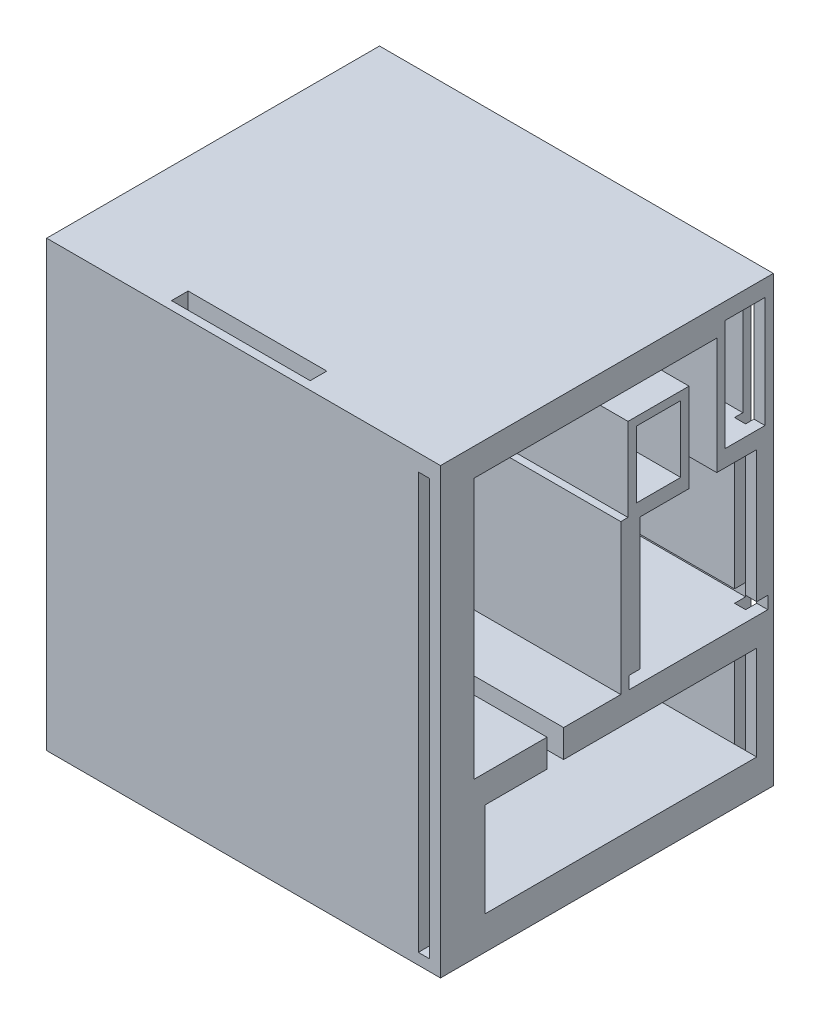
from build123d import *

# Parameters (mm, degrees)
SKETCH_1_W           = 75
SKETCH_1_H           = 80
EXTRUDE_1_DEPTH      = 60
CUT_EXTRUDE_2_DEPTH  = 70
CUT_EXTRUDE_3_DEPTH  = 70
CUT_EXTRUDE_4_DEPTH  = 50
CUT_EXTRUDE_5_DEPTH  = 70
SKETCH_4_W           = 2
SKETCH_4_H           = 75
CUT_EXTRUDE_6_DEPTH  = 3
SKETCH_6_W           = 25
SKETCH_6_H           = 3
CUT_EXTRUDE_7_DEPTH  = 127.249438863
SKETCH_7_W           = 3
SKETCH_7_H           = 2
CUT_EXTRUDE_8_DEPTH  = 3
SKETCH_9_W           = 60
SKETCH_9_H           = 80
CUT_EXTRUDE_11_DEPTH = 4
SKETCH_10_W          = 2
SKETCH_10_H          = 75
CUT_EXTRUDE_12_DEPTH = 3
SKETCH_8_W           = 8
SKETCH_8_H           = 12
SKETCH_8_W_2         = 7.2
SKETCH_8_H_2         = 20
CUT_EXTRUDE_13_DEPTH = 70


with BuildPart() as part:
    # 草图1 → 凸台-拉伸1 (new body)
    with BuildSketch(Plane.XY):
        with Locations((-39.564393939, 27.339015152)):
            Rectangle(SKETCH_1_W, SKETCH_1_H)
    extrude(amount=EXTRUDE_1_DEPTH)

    # 草图2<3> → 切除-拉伸2 (cut)
    with BuildSketch(Plane(origin=(-2.064393939, 0, 0), x_dir=(0, 0, -1), z_dir=(1, 0, 0))):
        Polygon((-54, 62.339015152), (-54, 42.339015152), (-26.2, 42.339015152), (-26.2, 57.339015152), (-15.2, 57.339015152), (-15.2, 41.339015152), (-10.2, 41.339015152), (-10.2, 62.339015152), align=None)
    extrude(amount=-CUT_EXTRUDE_2_DEPTH, mode=Mode.SUBTRACT)

    # 草图2<4> → 切除-拉伸3 (cut)
    with BuildSketch(Plane(origin=(-2.064393939, 0, 0), x_dir=(0, 0, -1), z_dir=(1, 0, 0))):
        Polygon((-27.5, 42.339015152), (-54, 42.339015152), (-54, 15.339015152), (-40.806060925, 15.339015152), (-37.806060925, 15.339015152), (-27.5, 15.339015152), align=None)
    extrude(amount=-CUT_EXTRUDE_3_DEPTH, mode=Mode.SUBTRACT)

    # 草图2<5> → 切除-拉伸4 (cut)
    with BuildSketch(Plane(origin=(-2.064393939, 0, 0), x_dir=(0, 0, -1), z_dir=(1, 0, 0))):
        Polygon((-24, 41.339015152), (-24, 17.589015152), (-26, 17.589015152), (-26, 15.339015152), (-1, 15.339015152), (-1, 17.589015152), (-3, 17.589015152), (-3, 41.339015152), align=None)
    extrude(amount=-CUT_EXTRUDE_4_DEPTH, mode=Mode.SUBTRACT)

    # 草图2 → 切除-拉伸5 (cut)
    with BuildSketch(Plane(origin=(-2.064393939, 0, 0), x_dir=(0, 0, -1), z_dir=(1, 0, 0))):
        Polygon((-37.806060925, 15.339015152), (-40.806060925, 15.339015152), (-40.806060925, 10.339015152), (-52, 10.339015152), (-52, -6.660984848), (-3, -6.660984848), (-3, 10.339015152), (-37.806060925, 10.339015152), align=None)
    extrude(amount=-CUT_EXTRUDE_5_DEPTH, mode=Mode.SUBTRACT)

    # 草图4 → 切除-拉伸6 (cut)
    with BuildSketch(Plane(origin=(0, 0, 0), x_dir=(-1, 0, 0), z_dir=(0, 0, -1))):
        with Locations((5.064393939, 26.839015152)):
            Rectangle(SKETCH_4_W, SKETCH_4_H)
    extrude(amount=-CUT_EXTRUDE_6_DEPTH, mode=Mode.SUBTRACT)

    # 草图6 → 切除-拉伸7 (cut, through all)
    with BuildSketch(Plane(origin=(0, 67.339015152, 0), x_dir=(1, 0, 0), z_dir=(0, 1, 0))):
        with Locations((-39.564393939, -57)):
            Rectangle(SKETCH_6_W, SKETCH_6_H)
    extrude(amount=-CUT_EXTRUDE_7_DEPTH, mode=Mode.SUBTRACT)

    # 草图7 → 切除-拉伸8 (cut)
    with BuildSketch(Plane(origin=(-52.064393939, 0, 0), x_dir=(0, 0, -1), z_dir=(1, 0, 0))):
        with Locations((-13.75, 16.339015152)):
            Rectangle(SKETCH_7_W, SKETCH_7_H)
    extrude(amount=-CUT_EXTRUDE_8_DEPTH, mode=Mode.SUBTRACT)

    # 草图9 → 切除-拉伸11 (cut)
    with BuildSketch(Plane.ZY.offset(77.064393939)):
        with Locations((30, 27.339015152)):
            Rectangle(SKETCH_9_W, SKETCH_9_H)
    extrude(amount=-CUT_EXTRUDE_11_DEPTH, mode=Mode.SUBTRACT)

    # 草图10 → 切除-拉伸12 (cut)
    with BuildSketch(Plane.XY.offset(60)):
        with Locations((-5.064393939, 26.839015152)):
            Rectangle(SKETCH_10_W, SKETCH_10_H)
    extrude(amount=-CUT_EXTRUDE_12_DEPTH, mode=Mode.SUBTRACT)

    # 草图8 → 切除-拉伸13 (cut)
    with BuildSketch(Plane(origin=(-2.064393939, 0, 0), x_dir=(0, 0, -1), z_dir=(1, 0, 0))):
        with Locations((-20.7, 49.839015152)):
            Rectangle(SKETCH_8_W, SKETCH_8_H)
        with Locations((-5.1, 54.339015152)):
            Rectangle(SKETCH_8_W_2, SKETCH_8_H_2)
    extrude(amount=-CUT_EXTRUDE_13_DEPTH, mode=Mode.SUBTRACT)


solid = part.part
